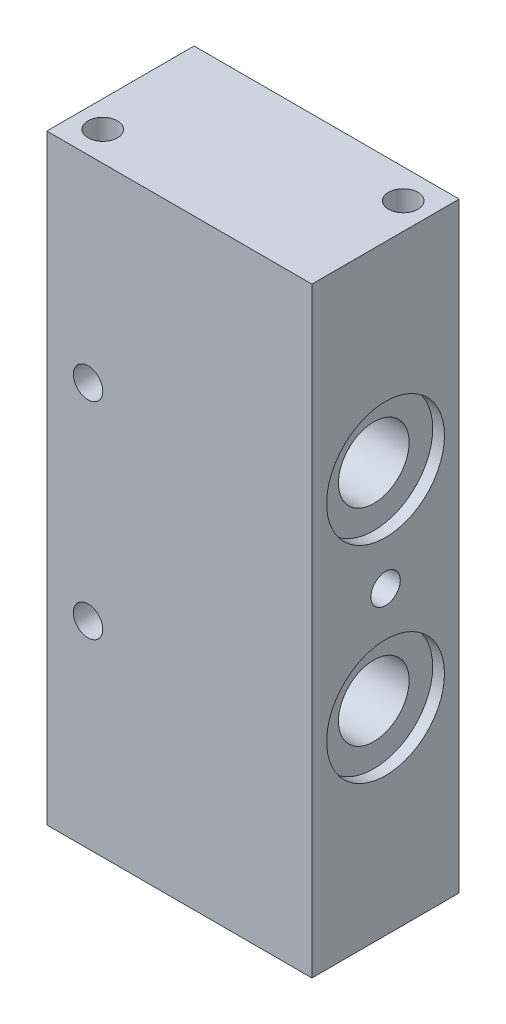
from build123d import *

# Parameters (mm, degrees)
SKETCH1_W           = 45
SKETCH1_H           = 25
BOSS_EXTRUDE1_DEPTH = 70
SKETCH2_R           = 6
CUT_EXTRUDE1_DEPTH  = 70
SKETCH3_R           = 10
CUT_EXTRUDE2_DEPTH  = 2
SKETCH4_R           = 10
CUT_EXTRUDE3_DEPTH  = 2
SKETCH5_R           = 2.5
CUT_EXTRUDE4_DEPTH  = 15
SKETCH6_R           = 2.5
CUT_EXTRUDE5_DEPTH  = 15
SKETCH7_R           = 2.5
CUT_EXTRUDE6_DEPTH  = 36
SKETCH8_R           = 2.5
CUT_EXTRUDE7_DEPTH  = 38
SKETCH9_W           = 45
SKETCH9_H           = 25
BOSS_EXTRUDE2_DEPTH = 16
SKETCH10_W          = 45
SKETCH10_H          = 25
BOSS_EXTRUDE3_DEPTH = 16
SKETCH11_R          = 2.5
BOSS_EXTRUDE4_DEPTH = 25
SKETCH12_R          = 2.5
BOSS_EXTRUDE5_DEPTH = 27
SKETCH13_R          = 2.5
CUT_EXTRUDE8_DEPTH  = 14


with BuildPart() as part:
    # Sketch1 → Boss-Extrude1 (new body)
    with BuildSketch(Plane(origin=(0, 0, 0), x_dir=(1, 0, 0), z_dir=(0, 1, 0))):
        Rectangle(SKETCH1_W, SKETCH1_H)
    extrude(amount=BOSS_EXTRUDE1_DEPTH)

    # Sketch2 → Cut-Extrude1 (cut)
    with BuildSketch(Plane(origin=(22.5, 0, 0), x_dir=(0, 0, -1), z_dir=(1, 0, 0))):
        with Locations((0, 52.5)):
            Circle(SKETCH2_R)
        with Locations((0, 17.5)):
            Circle(SKETCH2_R)
    extrude(amount=-CUT_EXTRUDE1_DEPTH, mode=Mode.SUBTRACT)

    # Sketch3 → Cut-Extrude2 (cut)
    with BuildSketch(Plane(origin=(22.5, 0, 0), x_dir=(0, 0, -1), z_dir=(1, 0, 0))):
        with Locations((0, 17.5)):
            Circle(SKETCH3_R)
        with Locations((0, 52.5)):
            Circle(SKETCH3_R)
    extrude(amount=-CUT_EXTRUDE2_DEPTH, mode=Mode.SUBTRACT)

    # Sketch4 → Cut-Extrude3 (cut)
    with BuildSketch(Plane.ZY.offset(22.5)):
        with Locations((0, 52.5)):
            Circle(SKETCH4_R)
        with Locations((0, 17.5)):
            Circle(SKETCH4_R)
    extrude(amount=-CUT_EXTRUDE3_DEPTH, mode=Mode.SUBTRACT)

    # Sketch5 → Cut-Extrude4 (cut)
    with BuildSketch(Plane(origin=(22.5, 0, 0), x_dir=(0, 0, -1), z_dir=(1, 0, 0))):
        with Locations((7.5, 6)):
            Circle(SKETCH5_R)
        with Locations((-7.5, 6)):
            Circle(SKETCH5_R)
        with Locations((7.5, 64)):
            Circle(SKETCH5_R)
        with Locations((-7.5, 64)):
            Circle(SKETCH5_R)
    extrude(amount=-CUT_EXTRUDE4_DEPTH, mode=Mode.SUBTRACT)

    # Sketch6 → Cut-Extrude5 (cut)
    with BuildSketch(Plane(origin=(22.5, 0, 0), x_dir=(0, 0, -1), z_dir=(1, 0, 0))):
        with Locations((0, 35)):
            Circle(SKETCH6_R)
    extrude(amount=-CUT_EXTRUDE5_DEPTH, mode=Mode.SUBTRACT)

    # Sketch7 → Cut-Extrude6 (cut)
    with BuildSketch(Plane.XY.offset(12.5)):
        with Locations((-15.5, 52.5)):
            Circle(SKETCH7_R)
        with Locations((-15.5, 17.5)):
            Circle(SKETCH7_R)
    extrude(amount=-CUT_EXTRUDE6_DEPTH, mode=Mode.SUBTRACT)

    # Sketch8 → Cut-Extrude7 (cut)
    with BuildSketch(Plane.XY.offset(12.5)):
        with Locations((-15.5, 64)):
            Circle(SKETCH8_R)
        with Locations((-15.5, 6)):
            Circle(SKETCH8_R)
    extrude(amount=-CUT_EXTRUDE7_DEPTH, mode=Mode.SUBTRACT)

    # Sketch9 → Boss-Extrude2 (add)
    with BuildSketch(Plane(origin=(0, 70, 0), x_dir=(1, 0, 0), z_dir=(0, 1, 0))):
        Rectangle(SKETCH9_W, SKETCH9_H)
    extrude(amount=BOSS_EXTRUDE2_DEPTH)

    # Sketch10 → Boss-Extrude3 (add)
    with BuildSketch(Plane.XZ):
        Rectangle(SKETCH10_W, SKETCH10_H)
    extrude(amount=BOSS_EXTRUDE3_DEPTH)

    # Sketch11 → Boss-Extrude4 (add)
    with BuildSketch(Plane(origin=(0, 0, -12.5), x_dir=(-1, 0, 0), z_dir=(0, 0, -1))):
        with Locations((15.5, 64)):
            Circle(SKETCH11_R)
        with Locations((15.5, 6)):
            Circle(SKETCH11_R)
    extrude(amount=-BOSS_EXTRUDE4_DEPTH)

    # Sketch12 → Boss-Extrude5 (add)
    with BuildSketch(Plane(origin=(22.5, 0, 0), x_dir=(0, 0, -1), z_dir=(1, 0, 0))):
        with Locations((-7.5, 64)):
            Circle(SKETCH12_R)
        with Locations((7.5, 64)):
            Circle(SKETCH12_R)
        with Locations((-7.5, 6)):
            Circle(SKETCH12_R)
        with Locations((7.5, 6)):
            Circle(SKETCH12_R)
    extrude(amount=-BOSS_EXTRUDE5_DEPTH)

    # Sketch13 → Cut-Extrude8 (cut)
    with BuildSketch(Plane(origin=(0, 86, 0), x_dir=(1, 0, 0), z_dir=(0, 1, 0))):
        with Locations((18, 7.5)):
            Circle(SKETCH13_R)
        with Locations((-18, -7.5)):
            Circle(SKETCH13_R)
    extrude(amount=-CUT_EXTRUDE8_DEPTH, mode=Mode.SUBTRACT)


solid = part.part
